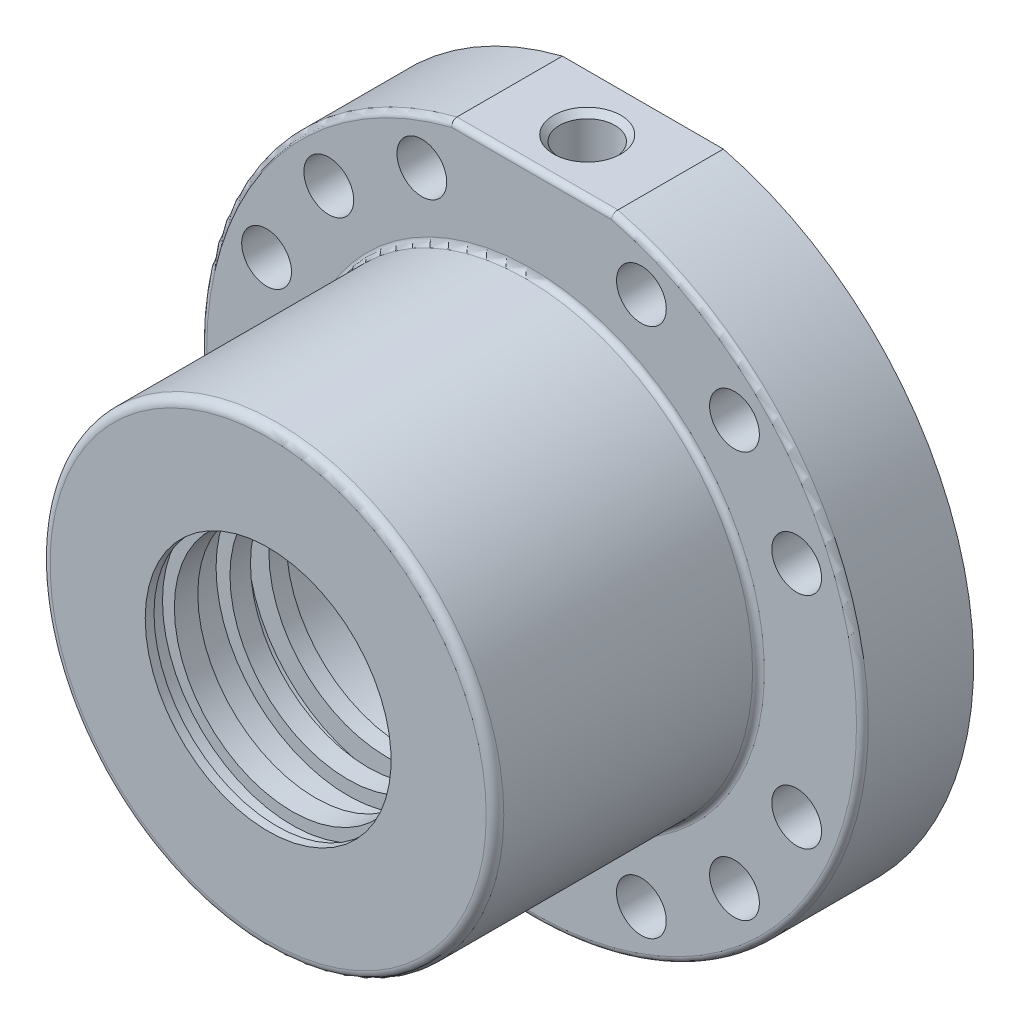
from build123d import *

# Parameters (mm, degrees)
SKETCH1_R                        = 113
BOSS_EXTRUDE1_DEPTH              = 74
SKETCH2_R                        = 129
SKETCH2_R_2                      = 70
CUT_EXTRUDE1_DEPTH               = 20
SKETCH3_W                        = 90
SKETCH3_H                        = 77.119146837
SKETCH6_W                        = 6
SKETCH6_H                        = 11.156401333
CHAMFER1_SIZE                    = 1
SKETCH9_W                        = 55
SKETCH9_H                        = 44.304211173
CUT_EXTRUDE2_DEPTH               = 122.5
F_1_2_14_NPSM_TAPPED_HOLE1_D     = 18.9738
F_1_2_14_NPSM_TAPPED_HOLE1_DEPTH = 100
F_1_2_14_NPSM_TAPPED_HOLE1_TIP   = 5.700304607
CHAMFER2_SIZE                    = 2
SKETCH13_R                       = 8.5
CUT_EXTRUDE3_DEPTH               = 59.0000001
CIRPATTERN3_COUNT                = 4
FILLET1_R                        = 2
FILLET2_R                        = 3


with BuildPart() as part:
    # Sketch1 → Boss-Extrude1 (new body, symmetric)
    with BuildSketch(Plane.XY):
        Circle(SKETCH1_R)
    extrude(amount=BOSS_EXTRUDE1_DEPTH, both=True)

    # Sketch2 → Cut-Extrude1 (cut)
    with BuildSketch(Plane(origin=(0, 0, -74), x_dir=(-1, 0, 0), z_dir=(0, 0, -1))):
        Circle(SKETCH2_R)
        Circle(SKETCH2_R_2, mode=Mode.SUBTRACT)
    extrude(amount=-CUT_EXTRUDE1_DEPTH, mode=Mode.SUBTRACT)

    # Sketch3 → Cut-Revolve1 (revolve, cut)
    with BuildSketch(Plane(origin=(0, 0, 0), x_dir=(0, 0, -1), z_dir=(1, 0, 0))):
        with Locations((-29, 116.059573419)):
            Rectangle(SKETCH3_W, SKETCH3_H)
    revolve(axis=Axis((0, 0, 0), (0, 0, 1)), mode=Mode.SUBTRACT)

    # Sketch6 → Cut-Revolve2 (revolve, cut)
    with BuildSketch(Plane(origin=(0, 0, 0), x_dir=(0, 0, -1), z_dir=(1, 0, 0))):
        with Locations((66, 71.578200667)):
            Rectangle(SKETCH6_W, SKETCH6_H)
    revolve(axis=Axis((0, 0, 0), (0, 0, -1)), mode=Mode.SUBTRACT)

    # Chamfer1
    chamfer1_edges = [part.edges().sort_by_distance(p)[0] for p in [
        (70, 0, -74),
    ]]
    chamfer(chamfer1_edges, length=CHAMFER1_SIZE)

    # Sketch9 → Cut-Extrude2 (cut, symmetric)
    with BuildSketch(Plane.XY):
        with Locations((0, 131.75479716)):
            Rectangle(SKETCH9_W, SKETCH9_H)
    extrude(amount=CUT_EXTRUDE2_DEPTH, both=True, mode=Mode.SUBTRACT)

    # 1/2-14 NPSM Tapped Hole1
    with Locations(Plane(origin=(0, 109.602691573, 0), x_dir=(1, 0, 0), z_dir=(0, 1, 0))):
        with Locations((0, 35)):
            Hole(F_1_2_14_NPSM_TAPPED_HOLE1_D / 2, depth=F_1_2_14_NPSM_TAPPED_HOLE1_DEPTH)
            with Locations((0, 0, -(F_1_2_14_NPSM_TAPPED_HOLE1_DEPTH + F_1_2_14_NPSM_TAPPED_HOLE1_TIP / 2))):  # 118° drill point
                Cone(0, F_1_2_14_NPSM_TAPPED_HOLE1_D / 2, F_1_2_14_NPSM_TAPPED_HOLE1_TIP, mode=Mode.SUBTRACT)

    # Sketch7 → Cut-Revolve3 (revolve, cut)
    with BuildSketch(Plane(origin=(0, 0, 0), x_dir=(0, -1, 0), z_dir=(1, 0, 0))):
        Polygon((-42, -74), (-42, -71), (-44.3, -71), (-44.3, -65.8), (-40.25, -65.8), (-40.25, -57.8), (-45, -57.8), (-45, -46.8), (-40.25, -46.8), (-40.25, -39.8), (-47.55, -39.8), (-47.55, -33.5), (-40.25, -33.5), (-40.25, -27.5), (-42.5, -27.5), (-42.5, 22.5), (-45, 22.5), (-45, 96.107724416), (-36.150119244, 96.107724416), (0, 96.107724416), (0, -74), align=None)
    revolve(axis=Axis((0, 0, 0), (0, 0, 1)), mode=Mode.SUBTRACT)

    # Chamfer2
    chamfer2_edges = [part.edges().sort_by_distance(p)[0] for p in [
        (9.4869, 109.602691573, -35),
    ]]
    chamfer(chamfer2_edges, length=CHAMFER2_SIZE)

    # Sketch13 → Cut-Extrude3 (cut, through all)
    with BuildSketch(Plane.XY.offset(-16)):
        with Locations((-69.296464556, 69.296464556)):
            Circle(SKETCH13_R)
        with Locations((-37.502976372, 90.540194186)):
            Circle(SKETCH13_R)
        with Locations((-90.540194186, 37.502976372)):
            Circle(SKETCH13_R)
    cut_extrude3 = extrude(amount=-CUT_EXTRUDE3_DEPTH, mode=Mode.SUBTRACT)

    # CirPattern3: Cut-Extrude3 ×4 about axis
    cirpattern3_axis = Axis((0, 0, 0), (0, 0, 1))
    for i in range(1, CIRPATTERN3_COUNT):
        add(cut_extrude3.rotate(cirpattern3_axis, i * 360 / CIRPATTERN3_COUNT), mode=Mode.SUBTRACT)

    # Fillet1
    fillet1_edges = [part.edges().sort_by_distance(p)[0] for p in [
        (0, -77.5, -16),
        (0, -113, -16),
        (0, 109.602691573, -16),
    ]]
    fillet(fillet1_edges, radius=FILLET1_R)

    # Fillet2
    fillet2_edges = [part.edges().sort_by_distance(p)[0] for p in [
        (0, -77.5, 74),
    ]]
    fillet(fillet2_edges, radius=FILLET2_R)


solid = part.part
